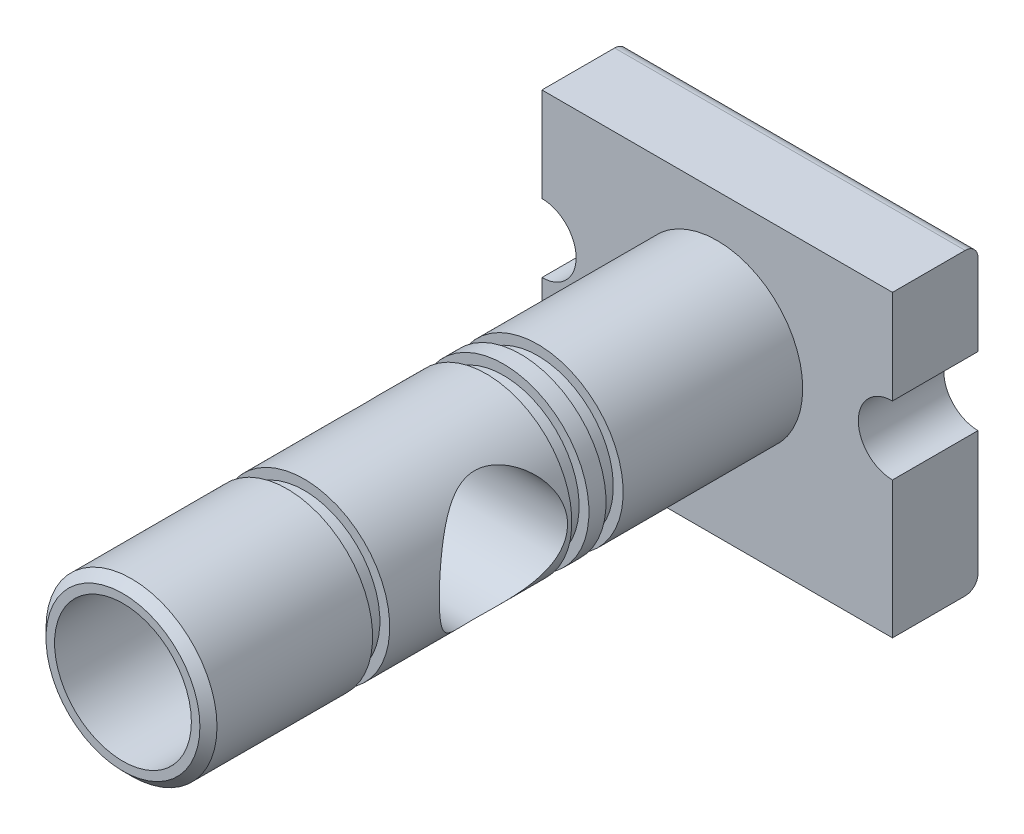
from build123d import *

# Parameters (mm, degrees)
BOSS_EXTRUDE1_DEPTH     = 20
SKETCH2_R               = 20
BOSS_EXTRUDE2_DEPTH     = 139
SKETCH3_R               = 15
CUT_EXTRUDE1_DEPTH      = 42
CUT_EXTRUDE1_DEPTH_BACK = 42
SKETCH4_W               = 4
SKETCH4_H               = 2.3
SKETCH5_R               = 16
CUT_EXTRUDE2_DEPTH      = 35.4
SKETCH6_R               = 9.5
CUT_EXTRUDE3_DEPTH      = 22
CHAMFER1_SIZE           = 2
FILLET1_R               = 3


with BuildPart() as part:
    # Sketch1 → Boss-Extrude1 (new body)
    with BuildSketch(Plane.XY):
        with BuildLine():
            Line((-41, -8), (-41, -40))
            Line((-41, -40), (41, -40))
            Line((41, -40), (41, -8))
            ThreePointArc((41, -8), (33, 0), (41, 8))
            Line((41, 8), (41, 30))
            Line((41, 30), (-41, 30))
            Line((-41, 30), (-41, 8))
            ThreePointArc((-41, 8), (-33, 0), (-41, -8))
        make_face()
    extrude(amount=BOSS_EXTRUDE1_DEPTH)

    # Sketch2 → Boss-Extrude2 (add)
    with BuildSketch(Plane.XY.offset(20)):
        Circle(SKETCH2_R)
    extrude(amount=BOSS_EXTRUDE2_DEPTH)

    # Sketch3 → Cut-Extrude1 (cut, two sides)
    with BuildSketch(Plane(origin=(0, 0, 0), x_dir=(0, 0, -1), z_dir=(1, 0, 0))) as cut_extrude1_sk:
        with Locations((-90, 0)):
            Circle(SKETCH3_R)
    extrude(amount=CUT_EXTRUDE1_DEPTH, mode=Mode.SUBTRACT)
    extrude(cut_extrude1_sk.sketch, amount=-CUT_EXTRUDE1_DEPTH_BACK, mode=Mode.SUBTRACT)

    # Sketch4 → Cut-Revolve1 (revolve, cut)
    with BuildSketch(Plane(origin=(0, 0, 0), x_dir=(0, 0, -1), z_dir=(1, 0, 0))):
        with Locations((-64, 18.85)):
            Rectangle(SKETCH4_W, SKETCH4_H)
        with Locations((-72, 18.85)):
            Rectangle(SKETCH4_W, SKETCH4_H)
        with Locations((-118.6, 18.85)):
            Rectangle(SKETCH4_W, SKETCH4_H)
    revolve(axis=Axis((0, 0, 0), (0, 0, 1)), mode=Mode.SUBTRACT)

    # Sketch5 → Cut-Extrude2 (cut)
    with BuildSketch(Plane.XY.offset(159)):
        Circle(SKETCH5_R)
    extrude(amount=-CUT_EXTRUDE2_DEPTH, mode=Mode.SUBTRACT)

    # Sketch6 → Cut-Extrude3 (cut)
    with BuildSketch(Plane.XY.offset(123.6)):
        Circle(SKETCH6_R)
    extrude(amount=-CUT_EXTRUDE3_DEPTH, mode=Mode.SUBTRACT)

    # Chamfer1
    chamfer1_edges = [part.edges().sort_by_distance(p)[0] for p in [
        (-20, 0, 159),
    ]]
    chamfer(chamfer1_edges, length=CHAMFER1_SIZE)

    # Fillet1
    fillet1_edges = [part.edges().sort_by_distance(p)[0] for p in [
        (0, -40, 0),
        (0, 30, 0),
    ]]
    fillet(fillet1_edges, radius=FILLET1_R)


solid = part.part
